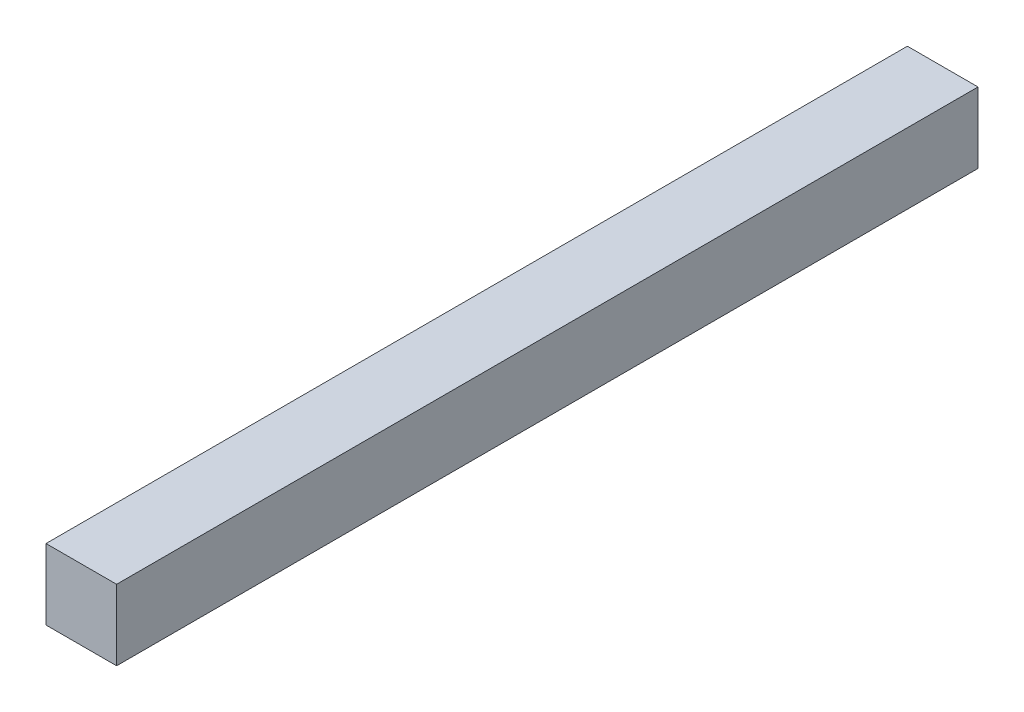
from build123d import *

# Parameters (mm, degrees)
SKETCH_1_W          = 10
SKETCH_1_H          = 10
EXTRUDE_1_DEPTH     = 122
SKETCH_2_R          = 4
CUT_EXTRUDE_1_DEPTH = 120
SKETCH_3_R          = 2
CUT_EXTRUDE_2_DEPTH = 2


with BuildPart() as part:
    # 草图1 → 凸台-拉伸1 (new body)
    with BuildSketch(Plane.XY):
        Rectangle(SKETCH_1_W, SKETCH_1_H)
    extrude(amount=EXTRUDE_1_DEPTH)

    # 草图2 → 切除-拉伸1 (cut)
    with BuildSketch(Plane(origin=(0, 0, 0), x_dir=(-1, 0, 0), z_dir=(0, 0, -1))):
        Circle(SKETCH_2_R)
    extrude(amount=-CUT_EXTRUDE_1_DEPTH, mode=Mode.SUBTRACT)

    # 草图3 → 切除-拉伸2 (cut)
    with BuildSketch(Plane.XZ.offset(5)):
        with Locations((0, 6.231427265)):
            Circle(SKETCH_3_R)
    extrude(amount=-CUT_EXTRUDE_2_DEPTH, mode=Mode.SUBTRACT)


solid = part.part
